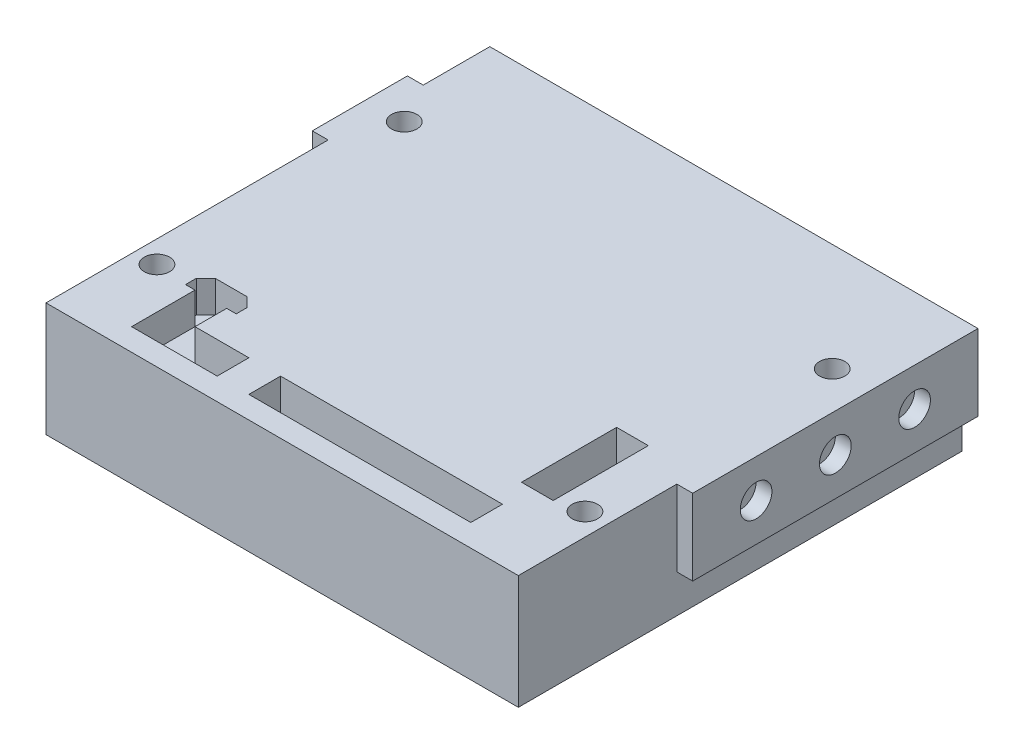
from build123d import *

# Parameters (mm, degrees)
SKETCH1_W           = 74.5
SKETCH1_H           = 70
BOSS_EXTRUDE1_DEPTH = 18
SKETCH3_W           = 5
SKETCH3_H           = 10
SKETCH3_W_2         = 8.5
SKETCH3_H_2         = 5
SKETCH3_W_3         = 18.5
SKETCH3_W_4         = 16.5
SKETCH3_H_3         = 15
CUT_EXTRUDE1_DEPTH  = 5
SKETCH4_W           = 45
SKETCH4_H           = 12
SKETCH4_R           = 2.5
BOSS_EXTRUDE2_DEPTH = 2.5
SKETCH5_W           = 15
SKETCH5_H           = 18
SKETCH5_R           = 2.5
BOSS_EXTRUDE3_DEPTH = 2.5
SKETCH6_R           = 2
CUT_EXTRUDE2_DEPTH  = 19


with BuildPart() as part:
    # Sketch1 → Boss-Extrude1 (new body)
    with BuildSketch(Plane(origin=(0, 0, 0), x_dir=(1, 0, 0), z_dir=(0, 1, 0))):
        Rectangle(SKETCH1_W, SKETCH1_H)
    extrude(amount=BOSS_EXTRUDE1_DEPTH)

    # Sketch3 → Cut-Extrude1 (cut)
    with BuildSketch(Plane(origin=(0, 18, 0), x_dir=(1, 0, 0), z_dir=(0, 1, 0))):
        with Locations((-24.75, -26.5)):
            Rectangle(SKETCH3_W, SKETCH3_H)
        with Locations((-18, -29)):
            Rectangle(SKETCH3_W_2, SKETCH3_H_2)
        Polygon((-28.75, -21.5), (-27.25, -21.5), (-22.25, -21.5), (-20.75, -21.5), (-20.75, -19.8), (-22.25, -18.3), (-27.25, -18.3), (-28.75, -19.8), align=None)
        with Locations((0.5, -29)):
            Rectangle(SKETCH3_W_3, SKETCH3_H_2)
        with Locations((18, -29)):
            Rectangle(SKETCH3_W_4, SKETCH3_H_2)
        with Locations((27.25, -14.5)):
            Rectangle(SKETCH3_W, SKETCH3_H_3)
    extrude(amount=-CUT_EXTRUDE1_DEPTH, mode=Mode.SUBTRACT)

    # Sketch4 → Boss-Extrude2 (add)
    with BuildSketch(Plane(origin=(37.25, 0, 0), x_dir=(0, 0, -1), z_dir=(1, 0, 0))):
        with Locations((12.5, 12)):
            Rectangle(SKETCH4_W, SKETCH4_H)
        with Locations((25, 12)):
            Circle(SKETCH4_R, mode=Mode.SUBTRACT)
        with Locations((12.5, 12)):
            Circle(SKETCH4_R, mode=Mode.SUBTRACT)
        with Locations((0, 12)):
            Circle(SKETCH4_R, mode=Mode.SUBTRACT)
    extrude(amount=BOSS_EXTRUDE2_DEPTH)

    # Sketch5 → Boss-Extrude3 (add)
    with BuildSketch(Plane.ZY.offset(37.25)):
        with Locations((-17, 9)):
            Rectangle(SKETCH5_W, SKETCH5_H)
        with Locations((-17, 12)):
            Circle(SKETCH5_R, mode=Mode.SUBTRACT)
        with Locations((-17, 6)):
            Circle(SKETCH5_R, mode=Mode.SUBTRACT)
    extrude(amount=BOSS_EXTRUDE3_DEPTH)

    # Sketch6 → Cut-Extrude2 (cut, through all)
    with BuildSketch(Plane.XZ):
        with Locations((-33.75, 21)):
            Circle(SKETCH6_R)
        with Locations((-33.75, -18)):
            Circle(SKETCH6_R)
    cut_extrude2 = extrude(amount=-CUT_EXTRUDE2_DEPTH, mode=Mode.SUBTRACT)

    # Mirror1: Cut-Extrude2 across plane
    add(cut_extrude2.mirror(Plane(origin=(0, 0, 0), x_dir=(0, 0, 1), z_dir=(1, 0, 0))), mode=Mode.SUBTRACT)


solid = part.part
